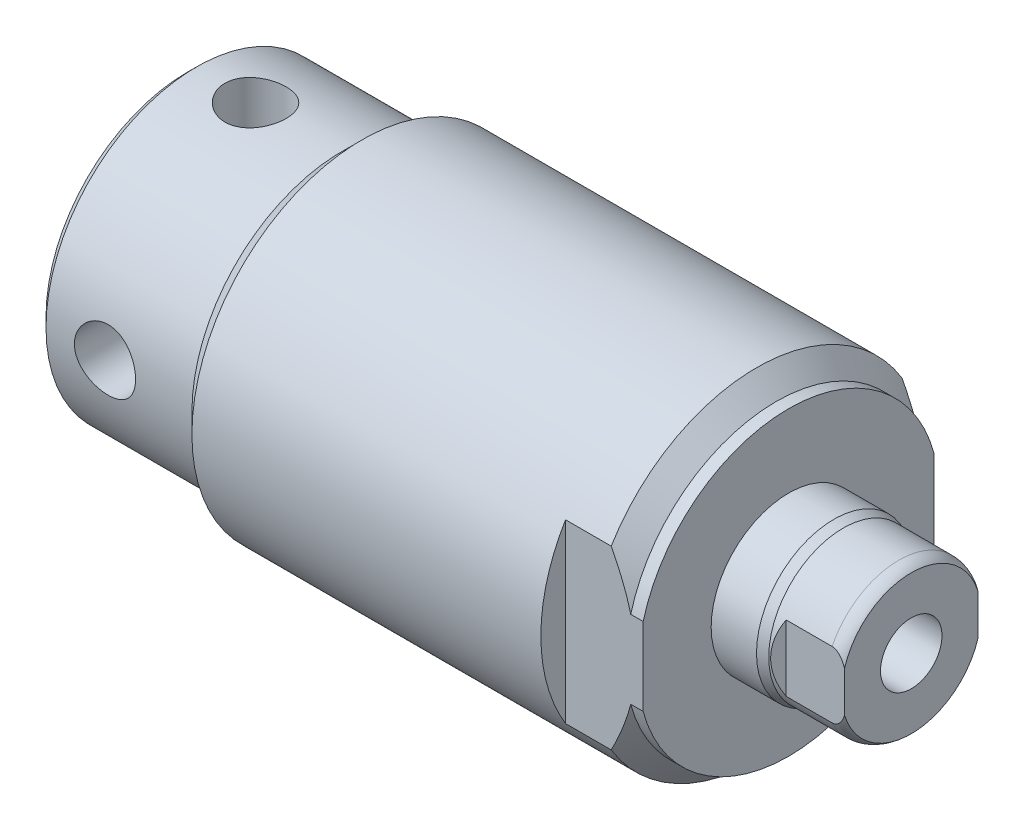
from build123d import *

# Parameters (mm, degrees)
CHAMFER1_SIZE           = 0.762
CUT_EXTRUDE1_DEPTH      = 14.919
CUT_EXTRUDE1_DEPTH_BACK = 14.919
HOLE1_D                 = 5.0038
HOLE1_DEPTH             = 4.064
CIRPATTERN1_COUNT       = 4
SKETCH6_W               = 6.35
SKETCH6_H               = 2.019
CUT_EXTRUDE2_DEPTH      = 14.919
CUT_EXTRUDE2_DEPTH_BACK = 14.919


with BuildPart() as part:
    # Sketch1 → Revolve1 (revolve)
    with BuildSketch(Plane(origin=(0, 0, 0), x_dir=(-1, 0, 0), z_dir=(0, 0, -1)), mode=Mode.PRIVATE) as revolve1_sk:
        with BuildLine():
            Line((-59.2328, 5.707922533), (-59.2328, 0))
            Line((-59.2328, 0), (0, 0))
            Line((0, 0), (0, 12.319))
            Line((0, 12.319), (-12.7, 12.319))
            Line((-12.7, 12.319), (-14.3, 13.919))
            Line((-14.3, 13.919), (-46.5838, 13.919))
            Line((-46.5838, 13.919), (-48.1838, 12.319))
            Line((-48.1838, 12.319), (-49.1998, 12.319))
            Line((-49.1998, 12.319), (-49.1998, 6.3373))
            Line((-49.1998, 6.3373), (-52.9082, 6.3373))
            Line((-52.9082, 6.3373), (-53.6702, 6.096))
            Line((-53.6702, 6.096), (-58.2168, 6.096))
            ThreePointArc((-58.2168, 6.096), (-58.760596865, 5.995678675), (-59.2328, 5.707922533))
        make_face()
    revolve(revolve1_sk.sketch.rotate(Axis((59.2328, 0, 0), (-1, 0, 0)), 270), axis=Axis((59.2328, 0, 0), (-1, 0, 0)))  # turned: the seam where the file's is

    # Sketch2 → Cut-Revolve1 (revolve, cut)
    with BuildSketch(Plane(origin=(0, 0, 0), x_dir=(-1, 0, 0), z_dir=(0, 0, -1)), mode=Mode.PRIVATE) as cut_revolve1_sk:
        Polygon((-10.5664, 0), (-10.5664, 4.4196), (-0.6604, 4.4196), (-0.127, 4.953), (0, 4.953), (0, 0), align=None)
    revolve(cut_revolve1_sk.sketch.rotate(Axis((33.143328407, 0, 0), (-1, 0, 0)), 270), axis=Axis((33.143328407, 0, 0), (-1, 0, 0)), mode=Mode.SUBTRACT)  # turned: the seam where the file's is

    # Sketch3 → Cut-Revolve2 (revolve, cut)
    with BuildSketch(Plane(origin=(0, 0, 0), x_dir=(-1, 0, 0), z_dir=(0, 0, -1)), mode=Mode.PRIVATE) as cut_revolve2_sk:
        Polygon((-59.2328, 2.5146), (-59.2328, 0), (-48.0568, 0), (-49.567724113, 2.5146), align=None)
    revolve(cut_revolve2_sk.sketch.rotate(Axis((66.313858967, 0, 0), (-1, 0, 0)), 270), axis=Axis((66.313858967, 0, 0), (-1, 0, 0)), mode=Mode.SUBTRACT)  # turned: the seam where the file's is

    # Chamfer1
    chamfer1_edges = [part.edges().sort_by_distance(p)[0] for p in [
        (0, 0, -12.319),
    ]]
    chamfer(chamfer1_edges, length=CHAMFER1_SIZE)

    # Sketch4 → Cut-Extrude1 (cut, two sides)
    with BuildSketch(Plane(origin=(0, 0, 0), x_dir=(1, 0, 0), z_dir=(0, 1, 0))) as cut_extrude1_sk:
        Polygon((53.8226, 6.096), (54.4576, 5.461), (59.2328, 5.461), (59.2328, 6.096), align=None)
        Polygon((59.2328, -6.096), (53.8226, -6.096), (54.4576, -5.461), (59.2328, -5.461), align=None)
    extrude(amount=CUT_EXTRUDE1_DEPTH, mode=Mode.SUBTRACT)
    extrude(cut_extrude1_sk.sketch, amount=-CUT_EXTRUDE1_DEPTH_BACK, mode=Mode.SUBTRACT)

    # Hole1
    with Locations(Plane(origin=(5.588, 12.319, 0), x_dir=(0, 0, 1), z_dir=(0, 1, 0))):
        with Locations((0, 0)):
            hole1 = Hole(HOLE1_D / 2, depth=HOLE1_DEPTH)

    # CirPattern1: Hole1 ×4 about axis
    cirpattern1_axis = Axis((0, 0, 0), (1, 0, 0))
    for i in range(1, CIRPATTERN1_COUNT):
        add(hole1.rotate(cirpattern1_axis, i * 360 / CIRPATTERN1_COUNT), mode=Mode.SUBTRACT)

    # Sketch6 → Cut-Extrude2 (cut, two sides)
    with BuildSketch(Plane(origin=(0, 0, 0), x_dir=(1, 0, 0), z_dir=(0, 1, 0))) as cut_extrude2_sk:
        with Locations((46.0248, 12.9095)):
            Rectangle(SKETCH6_W, SKETCH6_H)
        with Locations((46.0248, -12.9095)):
            Rectangle(SKETCH6_W, SKETCH6_H)
    extrude(amount=CUT_EXTRUDE2_DEPTH, mode=Mode.SUBTRACT)
    extrude(cut_extrude2_sk.sketch, amount=-CUT_EXTRUDE2_DEPTH_BACK, mode=Mode.SUBTRACT)


solid = part.part
